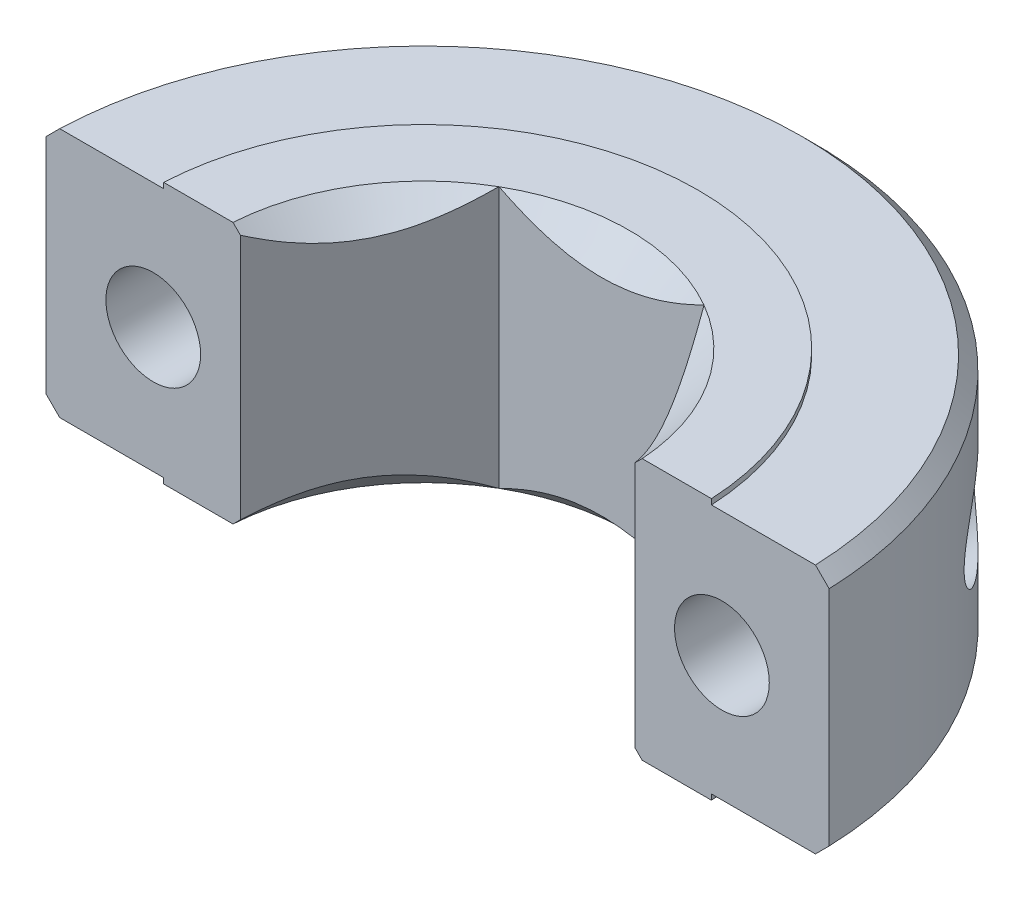
from build123d import *

# Parameters (mm, degrees)
BOSS_EXTRUDE1_DEPTH             = 9.525
CUT_EXTRUDE7_DEPTH              = 0.2
CUT_EXTRUDE8_DEPTH              = 0.2
F_29_0_136_DIAMETER_HOLE4_D     = 3.4544
F_29_0_136_DIAMETER_HOLE4_DEPTH = 13.7875
CHAMFER4_SIZE                   = 0.5


with BuildPart() as part:
    # Sketch19 → Boss-Extrude1 (new body)
    with BuildSketch(Plane(origin=(0, 4.7625, 0), x_dir=(1, 0, 0), z_dir=(0, 1, 0))):
        with BuildLine():
            Line((-14.278748413, 0.5), (-7.190320252, 0.5))
            Line((-7.190320252, 0.5), (-3.739497694, 6.477))
            Line((-3.739497694, 6.477), (3.739497694, 6.477))
            Line((3.739497694, 6.477), (7.190320252, 0.5))
            Line((7.190320252, 0.5), (14.278748413, 0.5))
            ThreePointArc((14.278748413, 0.5), (0, 14.2875), (-14.278748413, 0.5))
        make_face()
    extrude(amount=-BOSS_EXTRUDE1_DEPTH)

    # Sketch20 → Cut-Revolve1 (revolve, cut)
    with BuildSketch(Plane(origin=(0, 0, 0), x_dir=(0, -1, 0), z_dir=(-0.865794102, 0, -0.500400412))):
        Polygon((4.7625, 0), (3.7625, 0), (3.7625, -6.477), (4.7625, -7.477), align=None)
    revolve(axis=Axis((0, -4.7625, 0), (0, 1, 0)), mode=Mode.SUBTRACT)

    # Sketch21 → Cut-Revolve2 (revolve, cut)
    with BuildSketch(Plane(origin=(0, 0, 0), x_dir=(0, 1, 0), z_dir=(0.06687174, 0, 0.99776158))):
        Polygon((4.7625, -7.477), (4.7625, 0), (3.7625, 0), (3.7625, -6.477), align=None)
    revolve(axis=Axis((0, 4.7625, 0), (0, -1, 0)), mode=Mode.SUBTRACT)

    # Sketch26 → Cut-Extrude7 (cut)
    with BuildSketch(Plane(origin=(0, 4.7625, 0), x_dir=(1, 0, 0), z_dir=(0, 1, 0))):
        with BuildLine():
            Line((-14.278748413, 0.5), (-9.987492178, 0.5))
            ThreePointArc((-9.987492178, 0.5), (0, 10), (9.987492178, 0.5))
            Line((9.987492178, 0.5), (14.278748413, 0.5))
            ThreePointArc((14.278748413, 0.5), (0, 14.2875), (-14.278748413, 0.5))
        make_face()
    extrude(amount=-CUT_EXTRUDE7_DEPTH, mode=Mode.SUBTRACT)

    # Sketch27 → Cut-Extrude8 (cut)
    with BuildSketch(Plane.XZ.offset(4.7625)):
        with BuildLine():
            Line((-9.987492178, -0.5), (-14.278748413, -0.5))
            ThreePointArc((-14.278748413, -0.5), (0, -14.2875), (14.278748413, -0.5))
            Line((14.278748413, -0.5), (9.987492178, -0.5))
            ThreePointArc((9.987492178, -0.5), (0, -10), (-9.987492178, -0.5))
        make_face()
    extrude(amount=-CUT_EXTRUDE8_DEPTH, mode=Mode.SUBTRACT)

    # #29 (0.136) Diameter Hole4
    with Locations(Plane.XY.offset(-0.5)):
        with Locations((-10.368210259, 0), (10.368210259, 0)):
            Hole(F_29_0_136_DIAMETER_HOLE4_D / 2, depth=F_29_0_136_DIAMETER_HOLE4_DEPTH)

    # Chamfer4
    chamfer4_edges = [part.edges().sort_by_distance(p)[0] for p in [
        (0, 4.5625, -14.2875),
        (0, -4.5625, -14.2875),
    ]]
    chamfer(chamfer4_edges, length=CHAMFER4_SIZE)


solid = part.part
